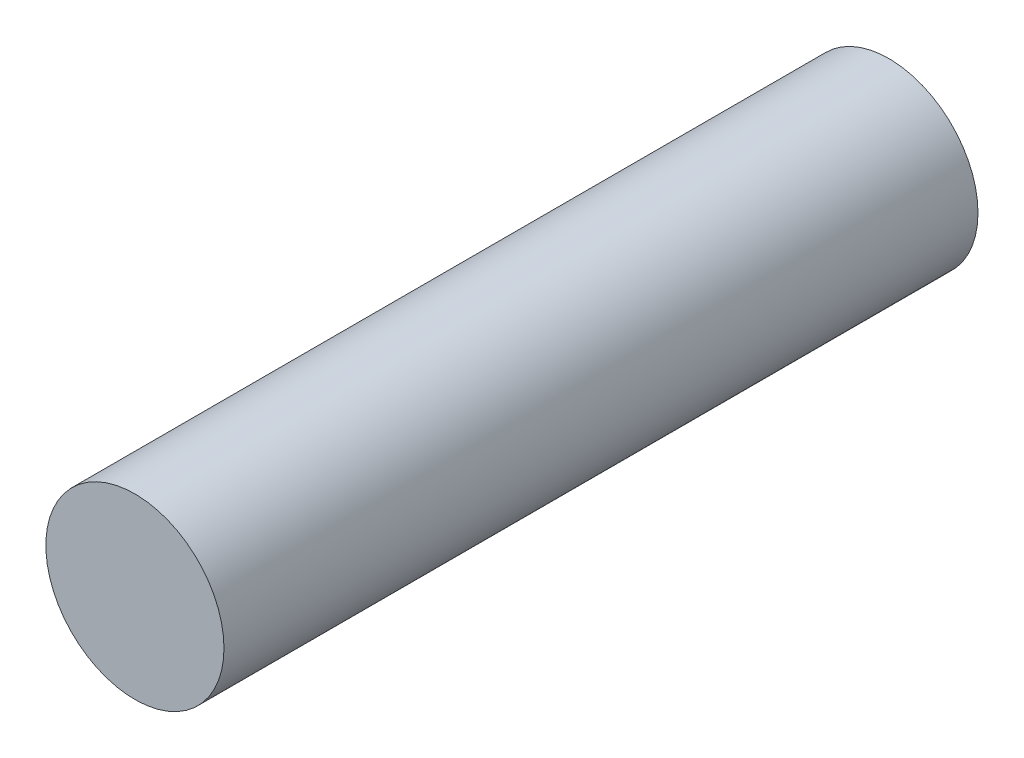
from build123d import *

# Parameters (mm, degrees)
SKETCH1_R           = 5.1308
BOSS_EXTRUDE1_DEPTH = 43.434


with BuildPart() as part:
    # Sketch1 → Boss-Extrude1 (new body)
    with BuildSketch(Plane.XY):
        Circle(SKETCH1_R)
    extrude(amount=BOSS_EXTRUDE1_DEPTH)


solid = part.part
